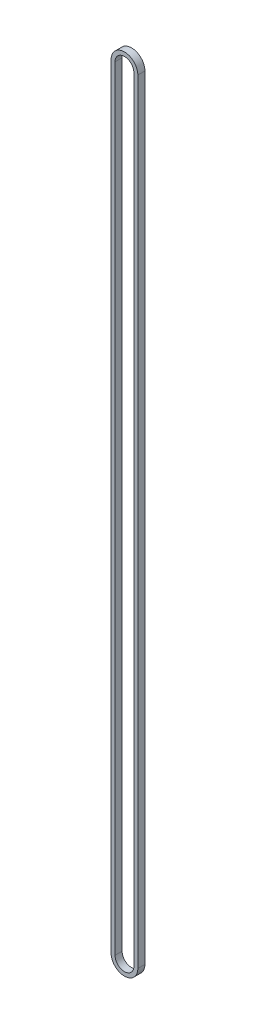
from build123d import *

# Parameters (mm, degrees)
EXTRUDE_1_DEPTH = 4.5


with BuildPart() as part:
    # Эскиз1 → Бобышка-Вытянуть1 (new body)
    with BuildSketch(Plane.XY):
        with BuildLine():
            Line((-8.5, -245.925), (-8.5, 245.925))
            ThreePointArc((-8.5, 245.925), (0, 254.425), (8.5, 245.925))
            Line((8.5, 245.925), (8.5, -245.925))
            ThreePointArc((8.5, -245.925), (0, -254.425), (-8.5, -245.925))
        make_face()
        with BuildLine():
            Line((-6, -245.925), (-6, 245.925))
            ThreePointArc((-6, 245.925), (0, 251.925), (6, 245.925))
            Line((6, 245.925), (6, -245.925))
            ThreePointArc((6, -245.925), (0, -251.925), (-6, -245.925))
        make_face(mode=Mode.SUBTRACT)
    extrude(amount=EXTRUDE_1_DEPTH)


solid = part.part
